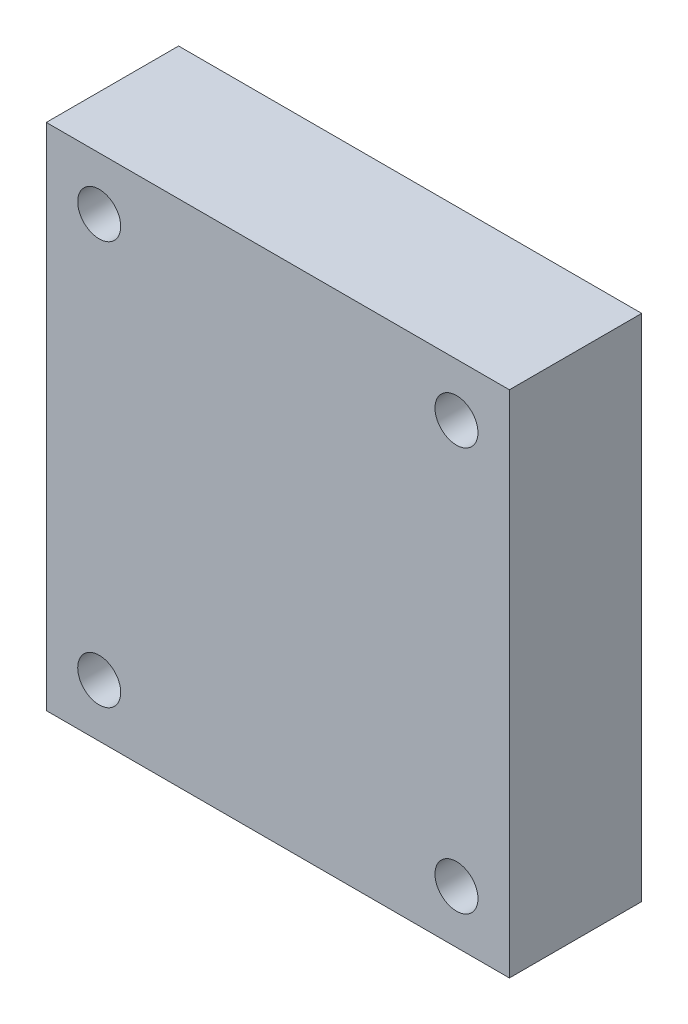
from build123d import *

# Parameters (mm, degrees)
SKETCH1_W           = 140
SKETCH1_H           = 154
SKETCH1_R           = 6.5
BOSS_EXTRUDE1_DEPTH = 20


with BuildPart() as part:
    # Sketch1 → Boss-Extrude1 (new body, symmetric)
    with BuildSketch(Plane.XY):
        Rectangle(SKETCH1_W, SKETCH1_H)
        with Locations((-54, 61)):
            Circle(SKETCH1_R, mode=Mode.SUBTRACT)
        with Locations((54, 61)):
            Circle(SKETCH1_R, mode=Mode.SUBTRACT)
        with Locations((54, -61)):
            Circle(SKETCH1_R, mode=Mode.SUBTRACT)
        with Locations((-54, -61)):
            Circle(SKETCH1_R, mode=Mode.SUBTRACT)
    extrude(amount=BOSS_EXTRUDE1_DEPTH, both=True)


solid = part.part
